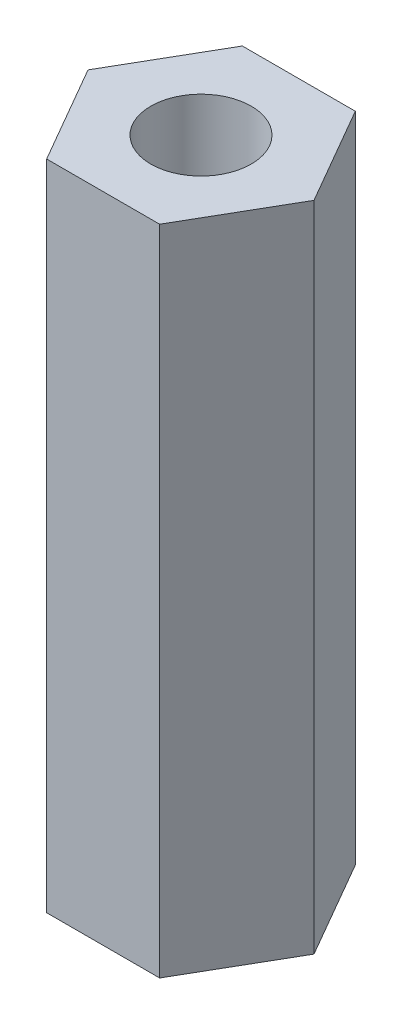
from build123d import *

# Parameters (mm, degrees)
SKETCH1_R           = 1
BOSS_EXTRUDE1_DEPTH = 13


with BuildPart() as part:
    # Sketch1 → Boss-Extrude1 (new body)
    with BuildSketch(Plane(origin=(0, 0, 0), x_dir=(1, 0, 0), z_dir=(0, 1, 0))):
        Polygon((2.25, 0), (1.125, 1.948557159), (-1.125, 1.948557159), (-2.25, 0), (-1.125, -1.948557159), (1.125, -1.948557159), align=None)
        Circle(SKETCH1_R, mode=Mode.SUBTRACT)
    extrude(amount=BOSS_EXTRUDE1_DEPTH)


solid = part.part
